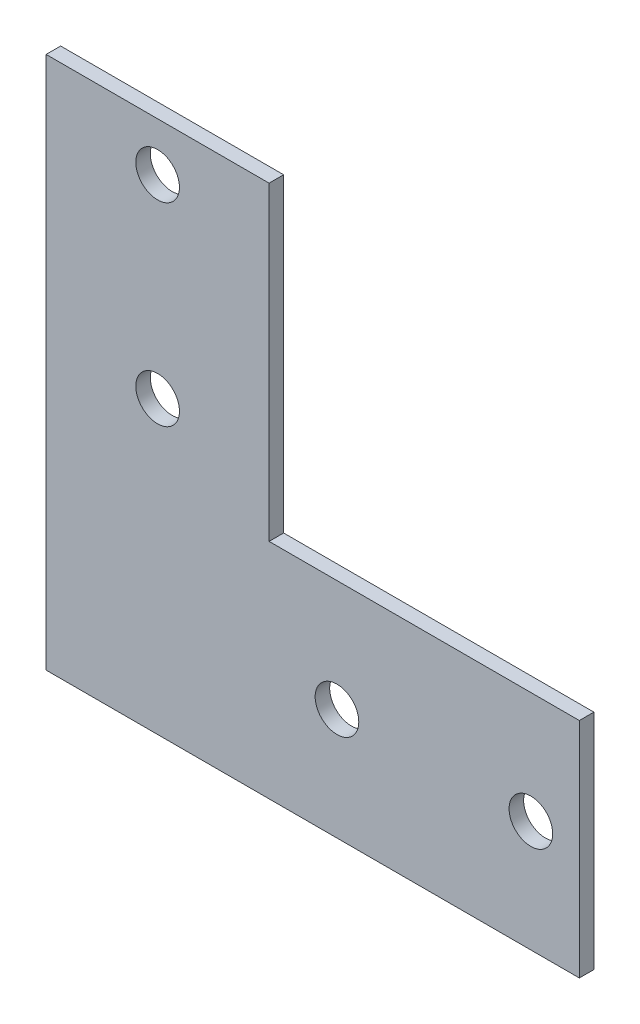
from build123d import *

# Parameters (mm, degrees)
SKETCH_1_R      = 4.5
EXTRUDE_1_DEPTH = 3


with BuildPart() as part:
    # Эскиз1 → Бобышка-Вытянуть1 (new body)
    with BuildSketch(Plane.XY):
        Polygon((0, 110), (0, 0), (110, 0), (110, 46), (46, 46), (46, 110), align=None)
        with Locations((23, 100)):
            Circle(SKETCH_1_R, mode=Mode.SUBTRACT)
        with Locations((23, 60)):
            Circle(SKETCH_1_R, mode=Mode.SUBTRACT)
        with Locations((60, 23)):
            Circle(SKETCH_1_R, mode=Mode.SUBTRACT)
        with Locations((100, 23)):
            Circle(SKETCH_1_R, mode=Mode.SUBTRACT)
    extrude(amount=EXTRUDE_1_DEPTH)


solid = part.part
